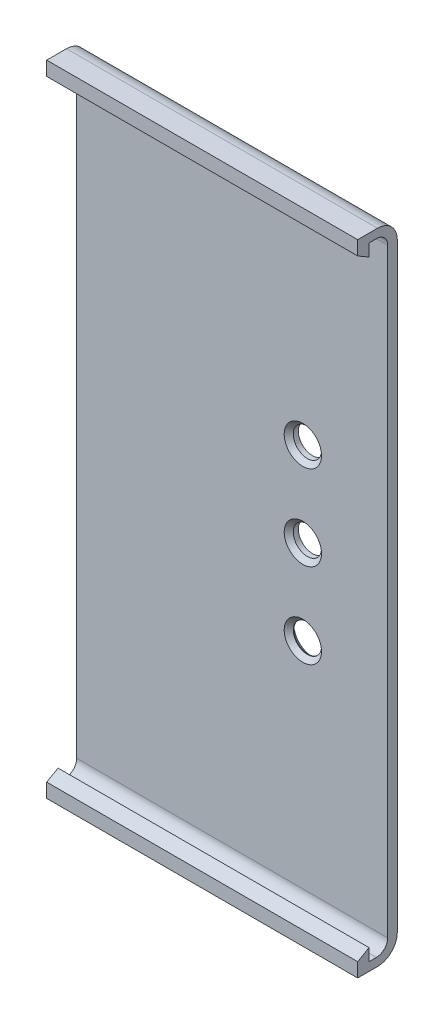
from build123d import *

# Parameters (mm, degrees)
BOSS_EXTRUDE1_DEPTH = 55
CUT_EXTRUDE1_REACH  = 3.7
SKETCH2_R           = 2.5
CHAMFER1_SIZE       = 0.8


with BuildPart() as part:
    # Sketch1 → Boss-Extrude1 (new body)
    with BuildSketch(Plane(origin=(0, 0, 0), x_dir=(0, 0, -1), z_dir=(1, 0, 0))):
        with BuildLine():
            Line((-69.749215448, 110.903184829), (-69.749215448, 113.057885367))
            Line((-69.749215448, 113.057885367), (-68.449215448, 113.057885367))
            ThreePointArc((-68.449215448, 113.057885367), (-67.035001885, 112.47209893), (-66.449215448, 111.057885367))
            Line((-66.449215448, 111.057885367), (-66.449215448, 4.973683681))
            ThreePointArc((-66.449215448, 4.973683681), (-67.035001885, 3.559470118), (-68.449215448, 2.973683681))
            Line((-68.449215448, 2.973683681), (-69.749215448, 2.973683681))
            Line((-69.749215448, 2.973683681), (-69.749215448, 5.128384219))
            Line((-69.749215448, 5.128384219), (-71.749215448, 3.973683681))
            Line((-71.749215448, 3.973683681), (-71.749215448, 1.473683681))
            Line((-71.749215448, 1.473683681), (-68.249215448, 1.473683681))
            ThreePointArc((-68.249215448, 1.473683681), (-65.774341713, 2.498809947), (-64.749215448, 4.973683681))
            Line((-64.749215448, 4.973683681), (-64.749215448, 111.057885367))
            ThreePointArc((-64.749215448, 111.057885367), (-65.774341713, 113.532759101), (-68.249215448, 114.557885367))
            Line((-68.249215448, 114.557885367), (-71.749215448, 114.557885367))
            Line((-71.749215448, 114.557885367), (-71.749215448, 112.057885367))
            Line((-71.749215448, 112.057885367), (-69.749215448, 110.903184829))
        make_face()
    extrude(amount=BOSS_EXTRUDE1_DEPTH)

    # Sketch2 → Cut-Extrude1 (cut, up to next)
    with BuildSketch(Plane.XY.offset(66.449215448), mode=Mode.PRIVATE) as cut_extrude1_sk1:
        with Locations((40, 72.973683681)):
            Circle(SKETCH2_R)
    cut_extrude1_tool1 = extrude(cut_extrude1_sk1.sketch, amount=-CUT_EXTRUDE1_REACH, mode=Mode.PRIVATE) & part.part
    add(cut_extrude1_tool1.solids().sort_by_distance((40, 72.973684, 66.449215))[0], mode=Mode.SUBTRACT)
    # Sketch2 → Cut-Extrude1 (cut, up to next)
    with BuildSketch(Plane.XY.offset(66.449215448), mode=Mode.PRIVATE) as cut_extrude1_sk2:
        with Locations((40, 57.973683681)):
            Circle(SKETCH2_R)
    cut_extrude1_tool2 = extrude(cut_extrude1_sk2.sketch, amount=-CUT_EXTRUDE1_REACH, mode=Mode.PRIVATE) & part.part
    add(cut_extrude1_tool2.solids().sort_by_distance((40, 57.973684, 66.449215))[0], mode=Mode.SUBTRACT)
    # Sketch2 → Cut-Extrude1 (cut, up to next)
    with BuildSketch(Plane.XY.offset(66.449215448), mode=Mode.PRIVATE) as cut_extrude1_sk3:
        with Locations((40, 42.973683681)):
            Circle(SKETCH2_R)
    cut_extrude1_tool3 = extrude(cut_extrude1_sk3.sketch, amount=-CUT_EXTRUDE1_REACH, mode=Mode.PRIVATE) & part.part
    add(cut_extrude1_tool3.solids().sort_by_distance((40, 42.973684, 66.449215))[0], mode=Mode.SUBTRACT)

    # Chamfer1
    chamfer1_edges = [part.edges().sort_by_distance(p)[0] for p in [
        (37.5, 72.973683681, 66.449215448),
        (37.5, 57.973683681, 66.449215448),
        (37.5, 42.973683681, 66.449215448),
        (37.5, 42.973683681, 64.749215448),
    ]]
    chamfer(chamfer1_edges, length=CHAMFER1_SIZE)


solid = part.part
